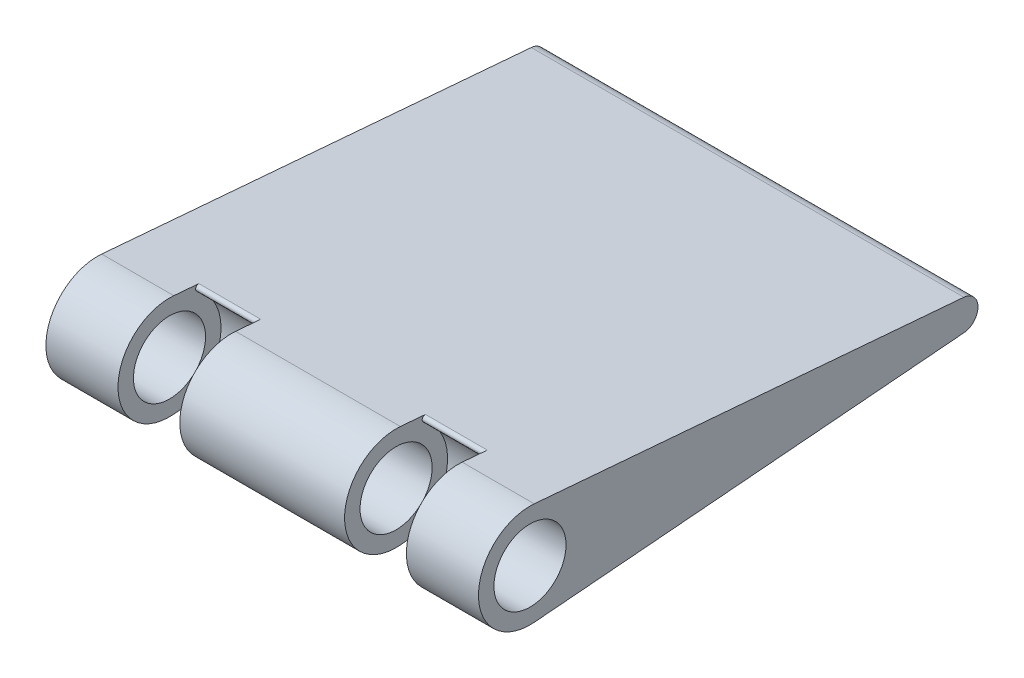
from build123d import *

# Parameters (mm, degrees)
SKETCH1_R           = 5
SKETCH1_R_2         = 3.5
SKETCH1_R_3         = 1.5
BOSS_EXTRUDE1_DEPTH = 21
CUT_EXTRUDE1_START  = 8
SKETCH1_3_R         = 5
CUT_EXTRUDE1_DEPTH  = 6
CUT_EXTRUDE2_START  = -8
SKETCH1_4_R         = 5
CUT_EXTRUDE2_DEPTH  = 6
FILLET1_R           = 0.3


with BuildPart() as part:
    # Sketch1 → Boss-Extrude1 (new body, symmetric)
    with BuildSketch(Plane(origin=(0, 0, 0), x_dir=(0, 0, -1), z_dir=(1, 0, 0))):
        with BuildLine():
            Line((42.125, 1.494782593), (0.416666667, 4.982608643))
            ThreePointArc((0.416666667, 4.982608643), (3.679900361, 3.385016002), (5, 0))
            ThreePointArc((5, 0), (3.679900361, -3.385016002), (0.416666667, -4.982608643))
            Line((0.416666667, -4.982608643), (42.125, -1.494782593))
            ThreePointArc((42.125, -1.494782593), (40.5, 0), (42.125, 1.494782593))
        make_face()
        Circle(SKETCH1_R)
        Circle(SKETCH1_R_2, mode=Mode.SUBTRACT)
        with Locations((42, 0)):
            Circle(SKETCH1_R_3)
    extrude(amount=BOSS_EXTRUDE1_DEPTH, both=True)

    # Sketch1_3 → Cut-Extrude1 (cut)
    with BuildSketch(Plane(origin=(0, 0, 0), x_dir=(0, 0, -1), z_dir=(1, 0, 0)).offset(CUT_EXTRUDE1_START)):
        Circle(SKETCH1_3_R)
    extrude(amount=CUT_EXTRUDE1_DEPTH, mode=Mode.SUBTRACT)

    # Sketch1_4 → Cut-Extrude2 (cut)
    with BuildSketch(Plane(origin=(0, 0, 0), x_dir=(0, 0, -1), z_dir=(1, 0, 0)).offset(CUT_EXTRUDE2_START)):
        Circle(SKETCH1_4_R)
    extrude(amount=-CUT_EXTRUDE2_DEPTH, mode=Mode.SUBTRACT)

    # Fillet1
    fillet1_edges = [part.edges().sort_by_distance(p)[0] for p in [
        (11, -4.982608643, -0.416666667),
        (11, 4.982608643, -0.416666667),
        (-11, 4.982608643, -0.416666667),
        (-11, -4.982608643, -0.416666667),
    ]]
    fillet(fillet1_edges, radius=FILLET1_R)


solid = part.part
